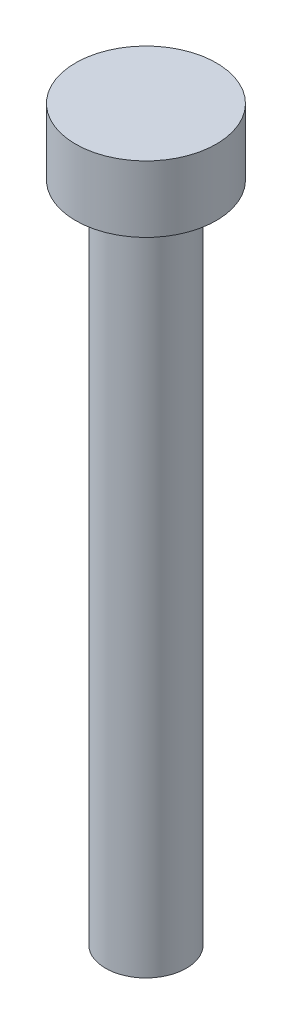
from build123d import *

# Parameters (mm, degrees)
SKETCH1_R           = 4.25
BOSS_EXTRUDE1_DEPTH = 4
SKETCH2_R           = 2.44
BOSS_EXTRUDE2_DEPTH = 40


with BuildPart() as part:
    # Sketch1 → Boss-Extrude1 (new body)
    with BuildSketch(Plane(origin=(0, 0, 0), x_dir=(1, 0, 0), z_dir=(0, 1, 0))):
        Circle(SKETCH1_R)
    extrude(amount=BOSS_EXTRUDE1_DEPTH)

    # Sketch2 → Boss-Extrude2 (add)
    with BuildSketch(Plane.XZ):
        Circle(SKETCH2_R)
    extrude(amount=BOSS_EXTRUDE2_DEPTH)


solid = part.part
